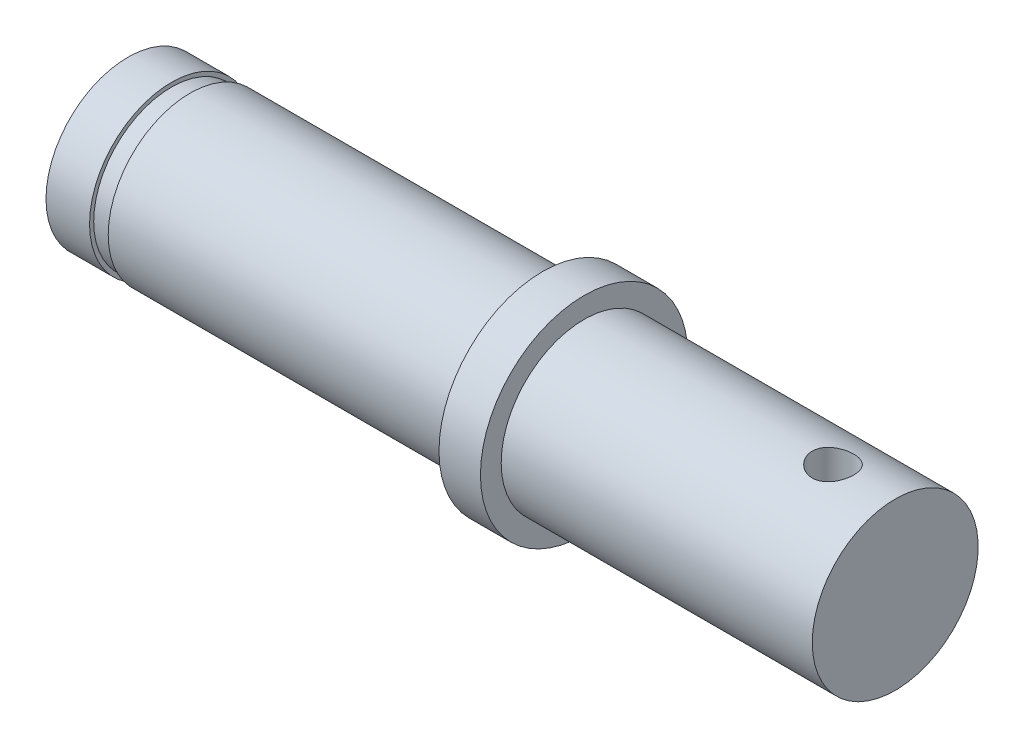
from build123d import *

# Parameters (mm, degrees)
SKETCH_2_R          = 1
CUT_EXTRUDE_1_DEPTH = 5


with BuildPart() as part:
    # 草图1 → 旋转1 (revolve)
    with BuildSketch(Plane.XY):
        Polygon((-15.499429975, 0), (21.500570025, 0), (21.500570025, 4), (6.500570025, 4), (6.500570025, 5), (4.500570025, 5), (4.500570025, 3.95), (-12.499429975, 3.95), (-12.499429975, 3.75), (-13.399429975, 3.75), (-13.399429975, 3.95), (-15.499429975, 3.95), align=None)
    revolve(axis=Axis((-15.499429975, 0, 0), (1, 0, 0)))

    # 草图2 → 切除-拉伸1 (cut, symmetric)
    with BuildSketch(Plane(origin=(0, 0, 0), x_dir=(1, 0, 0), z_dir=(0, 1, 0))):
        with Locations((18.500570025, 0)):
            Circle(SKETCH_2_R)
    extrude(amount=CUT_EXTRUDE_1_DEPTH, both=True, mode=Mode.SUBTRACT)


solid = part.part
